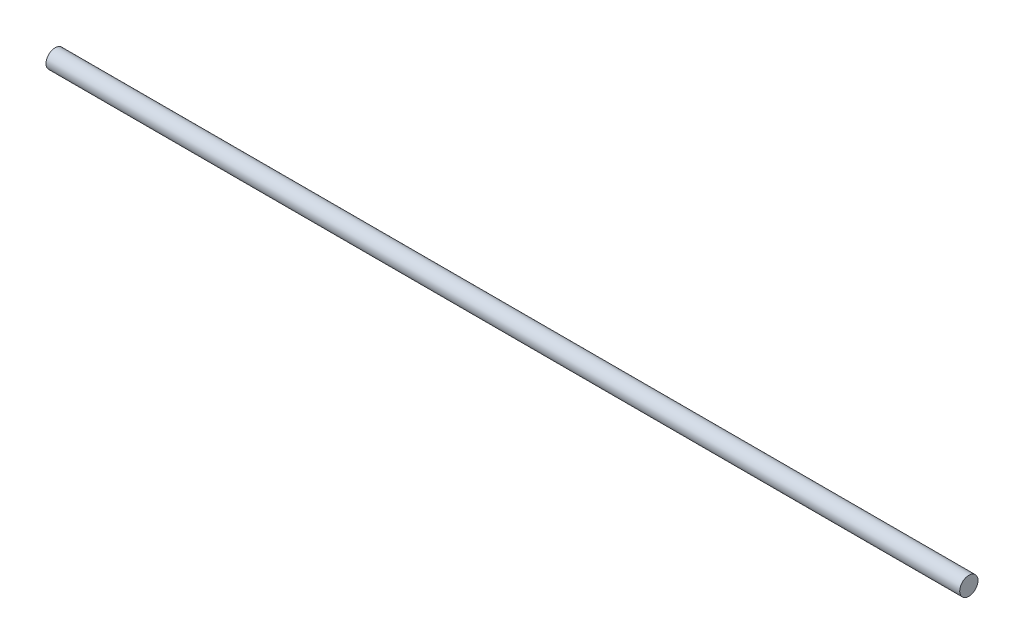
from build123d import *

# Parameters (mm, degrees)
SWEEP1_PROFILE_R = 6.35


with BuildPart() as part:
    # Sweep1: sweep along a path in Sketch1
    with BuildLine(Plane(origin=(0, 0, 0), x_dir=(1, 0, 0), z_dir=(0, 1, 0))) as sweep1_path:
        Line((0, 0), (635, 0))
    # Sweep1 profile (on start of the path) → Sweep1 (sweep)
    with BuildSketch(Plane(origin=(0, 0, 0), x_dir=(0, 0, 1), z_dir=(1, 0, 0))):
        Circle(SWEEP1_PROFILE_R)
    sweep(path=sweep1_path.line)


solid = part.part
